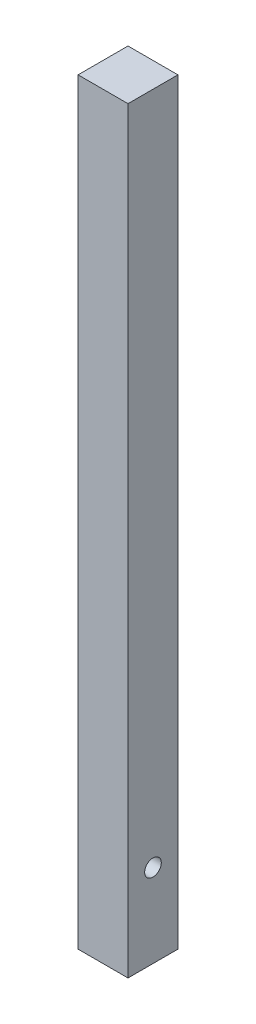
from build123d import *

# Parameters (mm, degrees)
CROQUIS1_W              = 38.1
CROQUIS1_H              = 38.1
SALIENTE_EXTRUIR1_DEPTH = 577.85
CROQUIS2_R              = 6.35
CORTAR_EXTRUIR1_DEPTH   = 12.7
CROQUIS4_R              = 6.35
CORTAR_EXTRUIR2_DEPTH   = 12.699746


with BuildPart() as part:
    # Croquis1 → Saliente-Extruir1 (new body)
    with BuildSketch(Plane(origin=(0, 0, 0), x_dir=(1, 0, 0), z_dir=(0, 1, 0))):
        Rectangle(CROQUIS1_W, CROQUIS1_H)
    extrude(amount=SALIENTE_EXTRUIR1_DEPTH)

    # Croquis2 → Cortar-Extruir1 (cut)
    with BuildSketch(Plane(origin=(19.05, 0, 0), x_dir=(0, 0, -1), z_dir=(1, 0, 0))):
        with Locations((0, 63.5)):
            Circle(CROQUIS2_R)
    extrude(amount=-CORTAR_EXTRUIR1_DEPTH, mode=Mode.SUBTRACT)

    # Croquis4 → Cortar-Extruir2 (cut)
    with BuildSketch(Plane(origin=(0, 0, -19.05), x_dir=(-1, 0, 0), z_dir=(0, 0, -1))):
        with Locations((0, 63.5)):
            Circle(CROQUIS4_R)
    extrude(amount=-CORTAR_EXTRUIR2_DEPTH, mode=Mode.SUBTRACT)


solid = part.part
